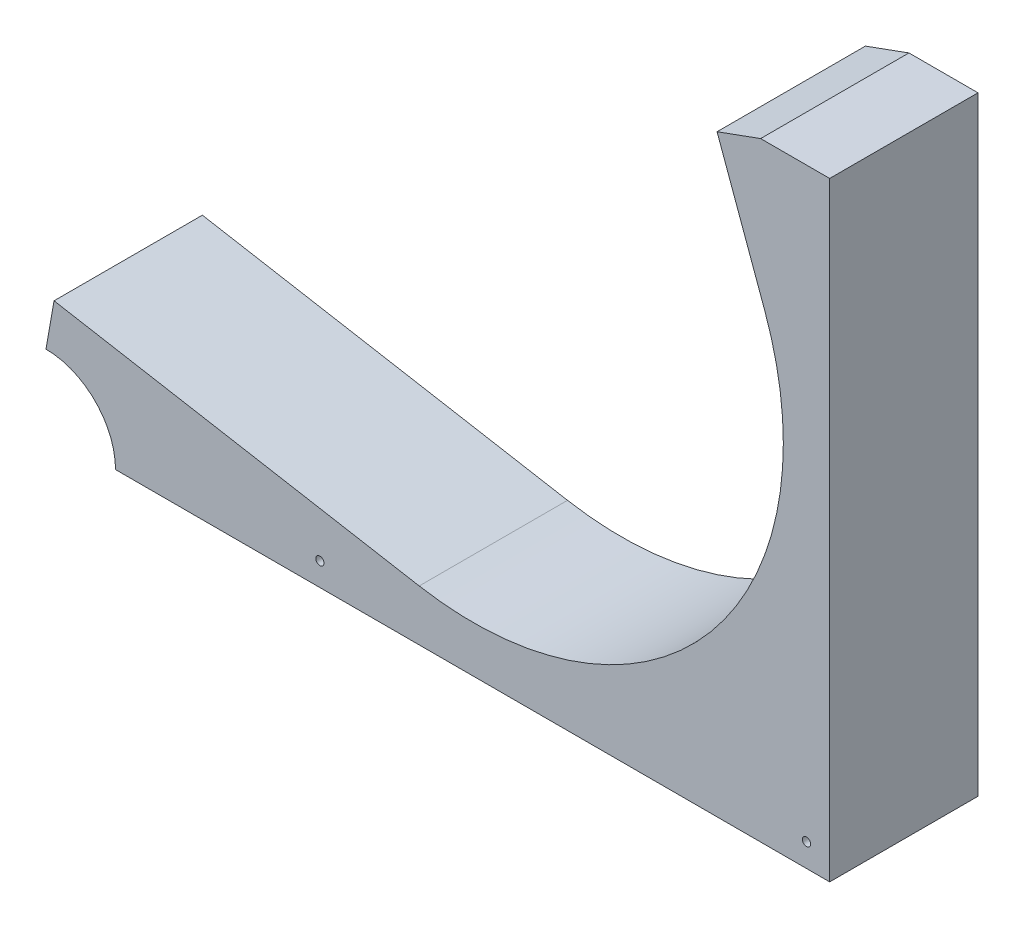
from build123d import *

# Parameters (mm, degrees)
BOSS_EXTRUDE1_DEPTH = 40.64
SKETCH6_R           = 1.1303
CUT_EXTRUDE1_DEPTH  = 158.779215984
SKETCH7_R           = 19.05
CUT_EXTRUDE2_DEPTH  = 158.779215984


with BuildPart() as part:
    # Sweep3: sweep along a path in Sketch2
    with BuildLine(Plane.XY) as sweep3_path:
        Line((-111.378641457, -46.568583299), (-11.322173751, -64.21123815))
        ThreePointArc((-11.322173751, -64.21123815), (49.947476571, -41.910909169), (61.269650322, 22.300328981))
        Line((61.269650322, 22.300328981), (48.238682861, 58.102617833))
    # 3DSketch1 → Sweep3 (sweep)
    with BuildSketch(Plane(origin=(-117.024291009, -78.586652965, -20.32), x_dir=(0.051794909001673446, 0.2937435257699459, 0.9544799780350292), z_dir=(0.984807753012208, -0.17364817766693055, 0))):
        Polygon((0, 0), (3.788092413, -12.121895721), (42.57815872, 0), (38.790066307, 12.121895721), align=None)
    sweep(path=sweep3_path.line)

    # Sketch5 → Boss-Extrude1 (add)
    with BuildSketch(Plane.XY.offset(20.32)):
        with BuildLine():
            Line((-16.967823303, -96.229307816), (-117.024291009, -78.586652965))
            Line((-117.024291009, -78.586652965), (-117.024291009, -97.7138))
            Line((-117.024291009, -97.7138), (-1.15e-07, -97.7138))
            ThreePointArc((-1.15e-07, -97.7138), (-8.516318873, -97.341969485), (-16.967823303, -96.229307816))
        make_face()
        with BuildLine():
            ThreePointArc((97.7138, 1.15e-07), (69.094090596, -69.094090596), (-1.15e-07, -97.7138))
            Line((-1.15e-07, -97.7138), (97.7138, -97.7138))
            Line((97.7138, -97.7138), (97.7138, 1.15e-07))
        make_face()
        with BuildLine():
            ThreePointArc((91.820936809, 33.420087881), (96.229307806, 16.96782336), (97.7138, 1.15e-07))
            Line((97.7138, 1.15e-07), (97.7138, 69.222376733))
            Line((97.7138, 69.222376733), (78.789969348, 69.222376733))
            Line((78.789969348, 69.222376733), (91.820936809, 33.420087881))
        make_face()
    extrude(amount=-BOSS_EXTRUDE1_DEPTH)

    # Sketch6 → Cut-Extrude1 (cut, through all)
    with BuildSketch(Plane.XY.offset(20.32)):
        with Locations((91.3638, -91.3638)):
            Circle(SKETCH6_R)
        with Locations((-41.9735, -91.3638)):
            Circle(SKETCH6_R)
    extrude(amount=-CUT_EXTRUDE1_DEPTH, mode=Mode.SUBTRACT)

    # Sketch7 → Cut-Extrude2 (cut, through all)
    with BuildSketch(Plane.XY.offset(20.32)):
        with Locations((-117.024291009, -97.7138)):
            Circle(SKETCH7_R)
    extrude(amount=-CUT_EXTRUDE2_DEPTH, mode=Mode.SUBTRACT)


solid = part.part
